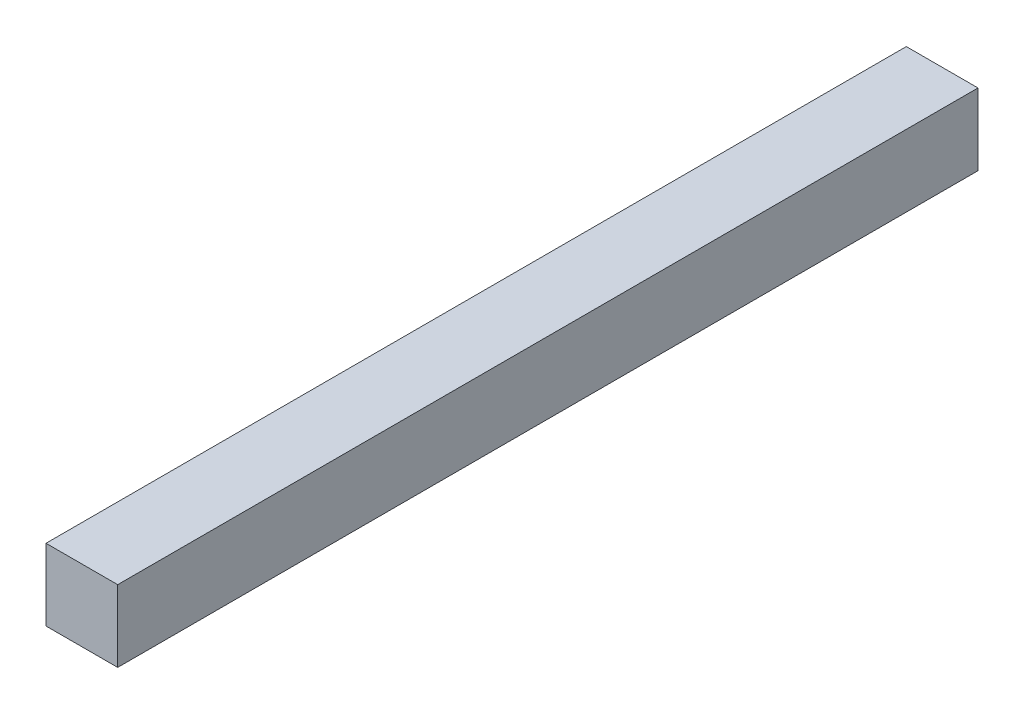
from build123d import *

# Parameters (mm, degrees)
ESBO_O1_W                = 50
ESBO_O1_H                = 50
RESSALTO_EXTRUS_O1_DEPTH = 600


with BuildPart() as part:
    # Esboço1 → Ressalto-extrusão1 (new body)
    with BuildSketch(Plane.XY):
        with Locations((-118.285485097, 36.153846154)):
            Rectangle(ESBO_O1_W, ESBO_O1_H)
    extrude(amount=RESSALTO_EXTRUS_O1_DEPTH)


solid = part.part
